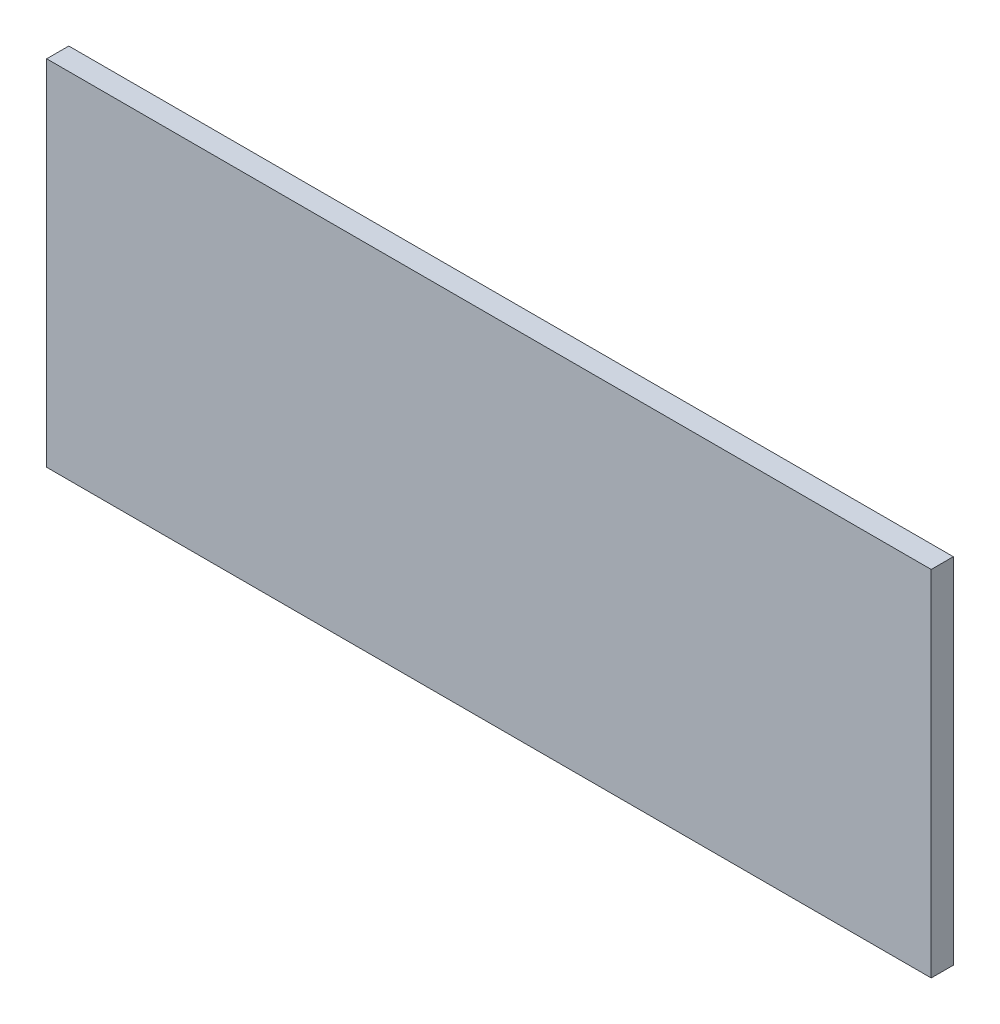
from build123d import *

# Parameters (mm, degrees)
SKETCH2_W           = 127
SKETCH2_H           = 50.8
BOSS_EXTRUDE1_DEPTH = 1.5875


with BuildPart() as part:
    # Sketch2 → Boss-Extrude1 (new body, symmetric)
    with BuildSketch(Plane.XY):
        Rectangle(SKETCH2_W, SKETCH2_H)
    extrude(amount=BOSS_EXTRUDE1_DEPTH, both=True)


solid = part.part
